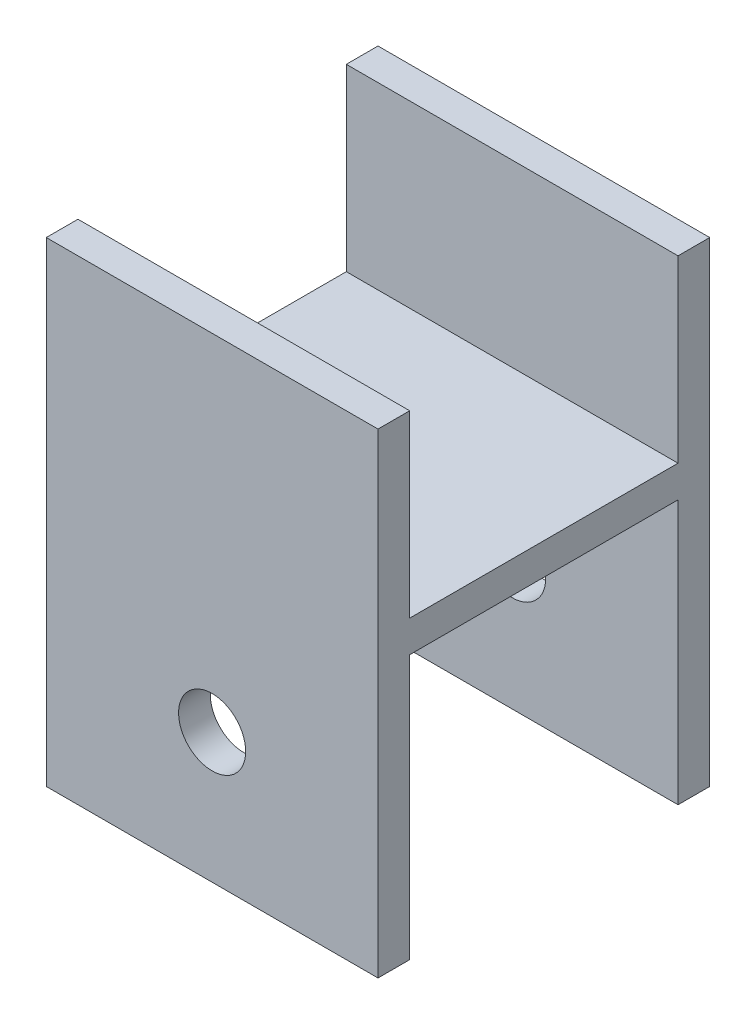
from build123d import *

# Parameters (mm, degrees)
BOSS_EXTRUDE1_DEPTH         = 31.4
F_1_4_0_25_DIAMETER_HOLE1_D = 6.35


with BuildPart() as part:
    # Sketch1 → Boss-Extrude1 (new body)
    with BuildSketch(Plane(origin=(0, 0, 0), x_dir=(0, 0, -1), z_dir=(1, 0, 0))):
        Polygon((0, 0), (0, 45), (3, 45), (3, 28), (28.4, 28), (28.4, 45), (31.4, 45), (31.4, 0), (28.4, 0), (28.4, 25), (3, 25), (3, 0), align=None)
    extrude(amount=BOSS_EXTRUDE1_DEPTH)

    # 1/4 (0.25) Diameter Hole1 (through all)
    with Locations(Plane.XY):
        with Locations((15.7, 12.3)):
            Hole(F_1_4_0_25_DIAMETER_HOLE1_D / 2)


solid = part.part
